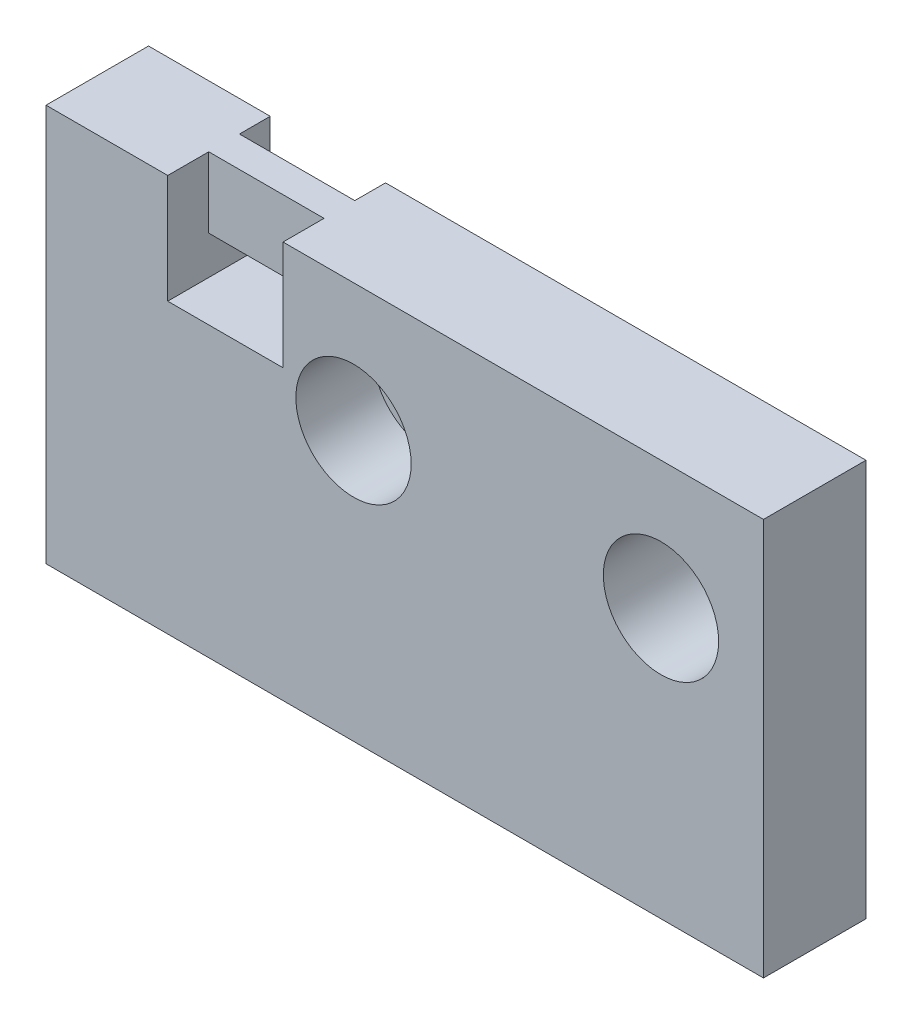
from build123d import *

# Parameters (mm, degrees)
SKETCH1_W           = 28
SKETCH1_H           = 15.5
BOSS_EXTRUDE1_DEPTH = 4
SKETCH2_R           = 1.25
CUT_EXTRUDE1_DEPTH  = 4
SKETCH3_R           = 2.25
CUT_EXTRUDE2_DEPTH  = 3
SKETCH4_W           = 4.5
SKETCH4_H           = 4.5
CUT_EXTRUDE3_DEPTH  = 1.6
SKETCH5_W           = 4.5
SKETCH5_H           = 1.5
CUT_EXTRUDE4_DEPTH  = 4
SKETCH6_W           = 4.5
SKETCH6_H           = 4.25
CUT_EXTRUDE5_DEPTH  = 1.2
SKETCH7_R           = 2.25
CUT_EXTRUDE6_DEPTH  = 10


with BuildPart() as part:
    # Sketch1 → Boss-Extrude1 (new body)
    with BuildSketch(Plane.XY):
        with Locations((14, -7.75)):
            Rectangle(SKETCH1_W, SKETCH1_H)
    extrude(amount=BOSS_EXTRUDE1_DEPTH)

    # Sketch2 → Cut-Extrude1 (cut)
    with BuildSketch(Plane.XY.offset(4)):
        with Locations((12, -5)):
            Circle(SKETCH2_R)
        with Locations((24, -5)):
            Circle(SKETCH2_R)
    extrude(amount=-CUT_EXTRUDE1_DEPTH, mode=Mode.SUBTRACT)

    # Sketch3 → Cut-Extrude2 (cut)
    with BuildSketch(Plane.XY.offset(4)):
        with Locations((12, -5)):
            Circle(SKETCH3_R)
        with Locations((24, -5)):
            Circle(SKETCH3_R)
    extrude(amount=-CUT_EXTRUDE2_DEPTH, mode=Mode.SUBTRACT)

    # Sketch4 → Cut-Extrude3 (cut)
    with BuildSketch(Plane.XY.offset(4)):
        with Locations((7, -2)):
            Rectangle(SKETCH4_W, SKETCH4_H)
    extrude(amount=-CUT_EXTRUDE3_DEPTH, mode=Mode.SUBTRACT)

    # Sketch5 → Cut-Extrude4 (cut)
    with BuildSketch(Plane.XY.offset(2.4)):
        with Locations((7, -3.5)):
            Rectangle(SKETCH5_W, SKETCH5_H)
    extrude(amount=-CUT_EXTRUDE4_DEPTH, mode=Mode.SUBTRACT)

    # Sketch6 → Cut-Extrude5 (cut)
    with BuildSketch(Plane(origin=(0, 0, 0), x_dir=(-1, 0, 0), z_dir=(0, 0, -1))):
        with Locations((-7, -2.125)):
            Rectangle(SKETCH6_W, SKETCH6_H)
    extrude(amount=-CUT_EXTRUDE5_DEPTH, mode=Mode.SUBTRACT)

    # Sketch7 → Cut-Extrude6 (cut)
    with BuildSketch(Plane.XY.offset(4)):
        with Locations((24, -5)):
            Circle(SKETCH7_R)
    extrude(amount=-CUT_EXTRUDE6_DEPTH, mode=Mode.SUBTRACT)


solid = part.part
